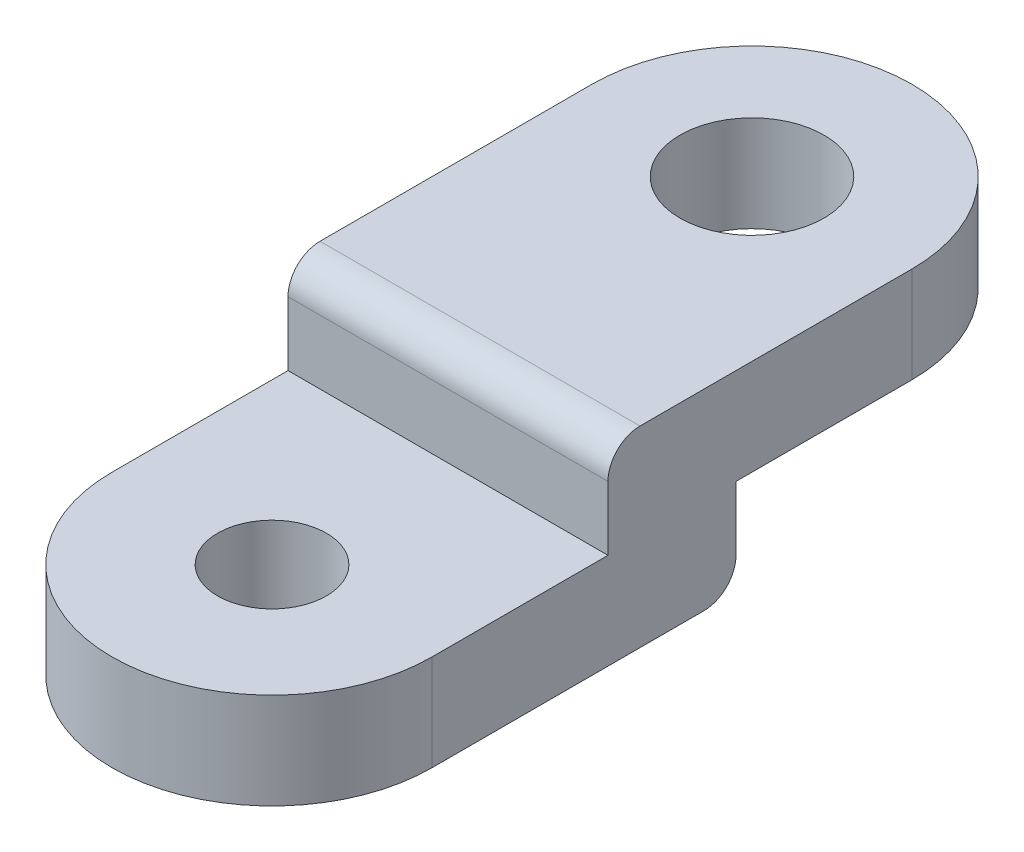
from build123d import *

# Parameters (mm, degrees)
BOSS_EXTRU_1_DEPTH      = 6
BOSS_EXTRU_2_DEPTH      = 12
ESQUISSE14_W            = 21
ESQUISSE14_H            = 6
ENL_V_MAT_EXTRU_2_DEPTH = 21
D_GAGEMENT_M81_D        = 9
TROU_TARAUD_M82_D       = 6.8
CONG_1_R                = 2


with BuildPart() as part:
    # Esquisse1 → Boss.-Extru.1 (new body)
    with BuildSketch(Plane(origin=(0, 0, 0), x_dir=(1, 0, 0), z_dir=(0, 1, 0))):
        with BuildLine():
            Line((0, 0), (0, 30))
            ThreePointArc((0, 30), (10, 40), (20, 30))
            Line((20, 30), (20, 0))
            ThreePointArc((20, 0), (10, -10), (0, 0))
        make_face()
    extrude(amount=BOSS_EXTRU_1_DEPTH)

    # Esquisse12 → Boss.-Extru.2 (add)
    with BuildSketch(Plane.XZ):
        with BuildLine():
            Line((0, -30), (20, -30))
            Line((20, -30), (20, 0))
            ThreePointArc((20, 0), (10, 10), (0, 0))
            Line((0, 0), (0, -30))
        make_face()
    extrude(amount=BOSS_EXTRU_2_DEPTH)

    # Esquisse14 → Enlèv. mat.-Extru.2 (cut, through all)
    with BuildSketch(Plane(origin=(20, 0, 0), x_dir=(0, 0, -1), z_dir=(1, 0, 0))):
        with Locations((0.5, 3)):
            Rectangle(ESQUISSE14_W, ESQUISSE14_H)
        Polygon((30, 0), (19, 0), (19, -6), (-10, -6), (-10, -12), (30, -12), align=None)
    extrude(amount=-ENL_V_MAT_EXTRU_2_DEPTH, mode=Mode.SUBTRACT)

    # Dégagement M81 (through all)
    with Locations(Plane(origin=(0, 6, 0), x_dir=(1, 0, 0), z_dir=(0, 1, 0))):
        with Locations((10, 30)):
            Hole(D_GAGEMENT_M81_D / 2)

    # Trou taraudé M82 (through all)
    with Locations(Plane(origin=(0, 0, 0), x_dir=(1, 0, 0), z_dir=(0, 1, 0))):
        with Locations((10, 0)):
            Hole(TROU_TARAUD_M82_D / 2)

    # Congé1
    cong_1_edges = [part.edges().sort_by_distance(p)[0] for p in [
        (10, -6, -19),
        (10, 6, -11),
    ]]
    fillet(cong_1_edges, radius=CONG_1_R)


solid = part.part
